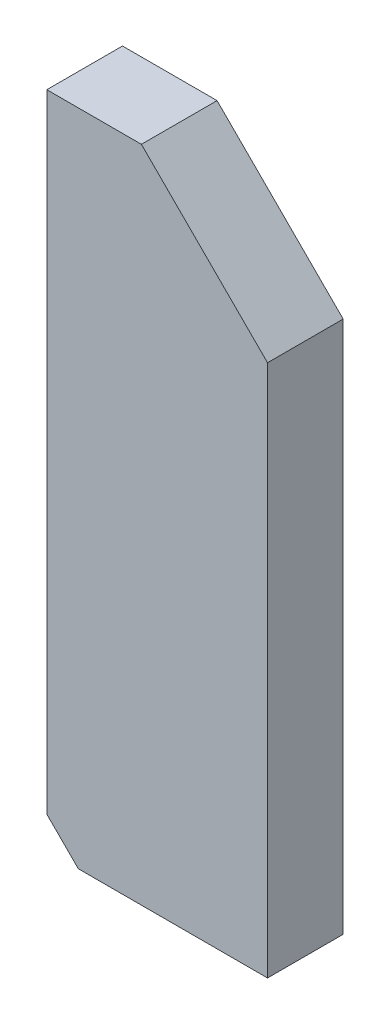
from build123d import *

# Parameters (mm, degrees)
BOSS_EXTRUDE1_DEPTH       = 12
M5X0_8_TAPPED_HOLE1_D     = 4.2
M5X0_8_TAPPED_HOLE1_DEPTH = 16
M5X0_8_TAPPED_HOLE1_TIP   = 1.2618073
M5X0_8_TAPPED_HOLE2_D     = 4.2
M5X0_8_TAPPED_HOLE2_DEPTH = 14
M5X0_8_TAPPED_HOLE2_TIP   = 1.2618073


with BuildPart() as part:
    # Sketch1 → Boss-Extrude1 (new body)
    with BuildSketch(Plane.XY):
        Polygon((15, 104.5), (35, 84.5), (35, 0), (5, 0), (0, 5), (0, 104.5), align=None)
    extrude(amount=BOSS_EXTRUDE1_DEPTH)

    # M5x0.8 Tapped Hole1
    with Locations(Plane.ZY):
        with Locations((6, 90), (6, 20)):
            Hole(M5X0_8_TAPPED_HOLE1_D / 2, depth=M5X0_8_TAPPED_HOLE1_DEPTH)
            with Locations((0, 0, -(M5X0_8_TAPPED_HOLE1_DEPTH + M5X0_8_TAPPED_HOLE1_TIP / 2))):  # 118° drill point
                Cone(0, M5X0_8_TAPPED_HOLE1_D / 2, M5X0_8_TAPPED_HOLE1_TIP, mode=Mode.SUBTRACT)

    # M5x0.8 Tapped Hole2
    with Locations(Plane.XZ):
        with Locations((25, 6)):
            Hole(M5X0_8_TAPPED_HOLE2_D / 2, depth=M5X0_8_TAPPED_HOLE2_DEPTH)
            with Locations((0, 0, -(M5X0_8_TAPPED_HOLE2_DEPTH + M5X0_8_TAPPED_HOLE2_TIP / 2))):  # 118° drill point
                Cone(0, M5X0_8_TAPPED_HOLE2_D / 2, M5X0_8_TAPPED_HOLE2_TIP, mode=Mode.SUBTRACT)


solid = part.part
